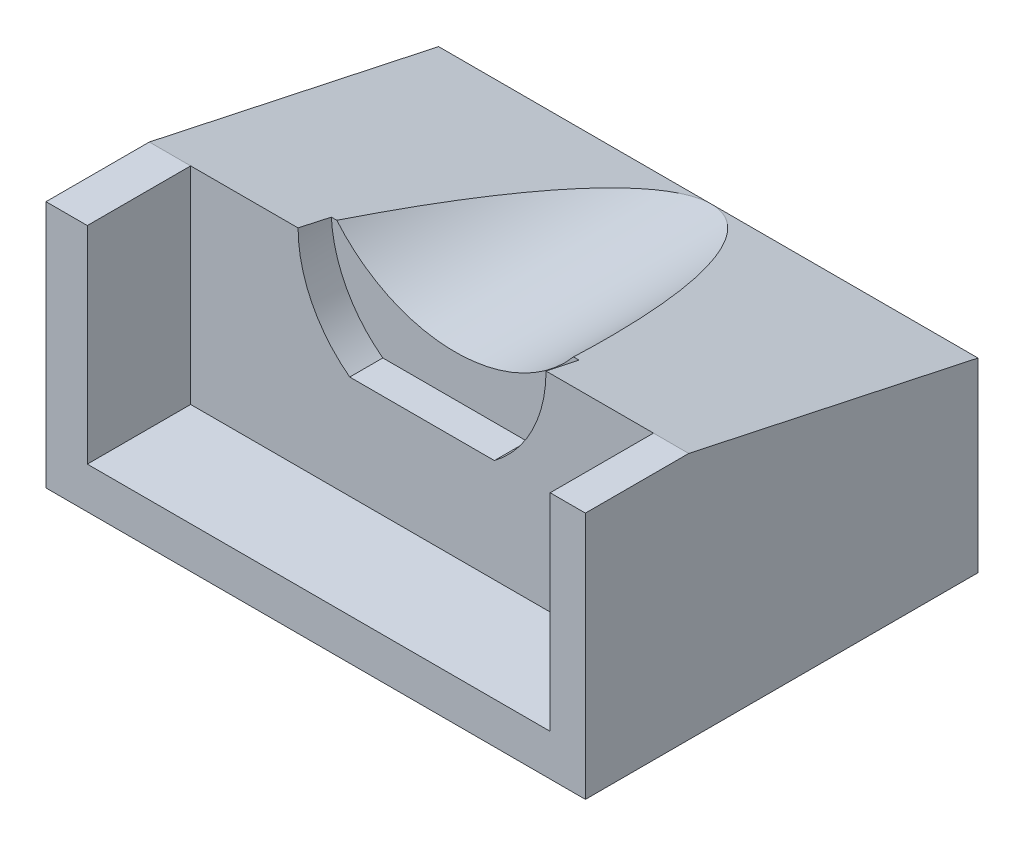
from build123d import *

# Parameters (mm, degrees)
SKETCH2_W           = 22.4
SKETCH2_H           = 10
BOSS_EXTRUDE1_DEPTH = 14
CUT_EXTRUDE2_DEPTH  = 1.6
CUT_EXTRUDE4_DEPTH  = 13.4
BOSS_EXTRUDE2_DEPTH = 19
CUT_EXTRUDE5_DEPTH  = 27.105381484


with BuildPart() as part:
    # Sketch2 → Boss-Extrude1 (new body)
    with BuildSketch(Plane.XY):
        Rectangle(SKETCH2_W, SKETCH2_H)
    extrude(amount=BOSS_EXTRUDE1_DEPTH)

    # Sketch3 → Cut-Extrude2 (cut)
    with BuildSketch(Plane.XY.offset(14)):
        with BuildLine():
            Line((-6, 5), (6, 5))
            ThreePointArc((6, 5), (5.340169944, 2.204915028), (3.5, 0))
            Line((3.5, 0), (-3.5, 0))
            ThreePointArc((-3.5, 0), (-5.340169944, 2.204915028), (-6, 5))
        make_face()
    extrude(amount=-CUT_EXTRUDE2_DEPTH, mode=Mode.SUBTRACT)

    # Sketch5 → Cut-Extrude4 (cut, through all)
    with BuildSketch(Plane.XY.offset(12.4)):
        with BuildLine():
            Line((-6, 5), (6, 5))
            ThreePointArc((6, 5), (0, 2), (-6, 5))
        make_face()
    extrude(amount=-CUT_EXTRUDE4_DEPTH, mode=Mode.SUBTRACT)

    # Sketch6 → Boss-Extrude2 (add)
    with BuildSketch(Plane.XY):
        Polygon((-11.2, 5), (-13.2, 5), (-13.2, -7), (12.905381484, -7), (12.905381484, 5), (11.2, 5), (11.2, -5), (-11.2, -5), align=None)
    extrude(amount=BOSS_EXTRUDE2_DEPTH)

    # Sketch7 → Cut-Extrude5 (cut, through all)
    with BuildSketch(Plane.ZY.offset(13.2)):
        Polygon((0, 5), (14, 5), (0, 2), align=None)
    extrude(amount=-CUT_EXTRUDE5_DEPTH, mode=Mode.SUBTRACT)


solid = part.part
